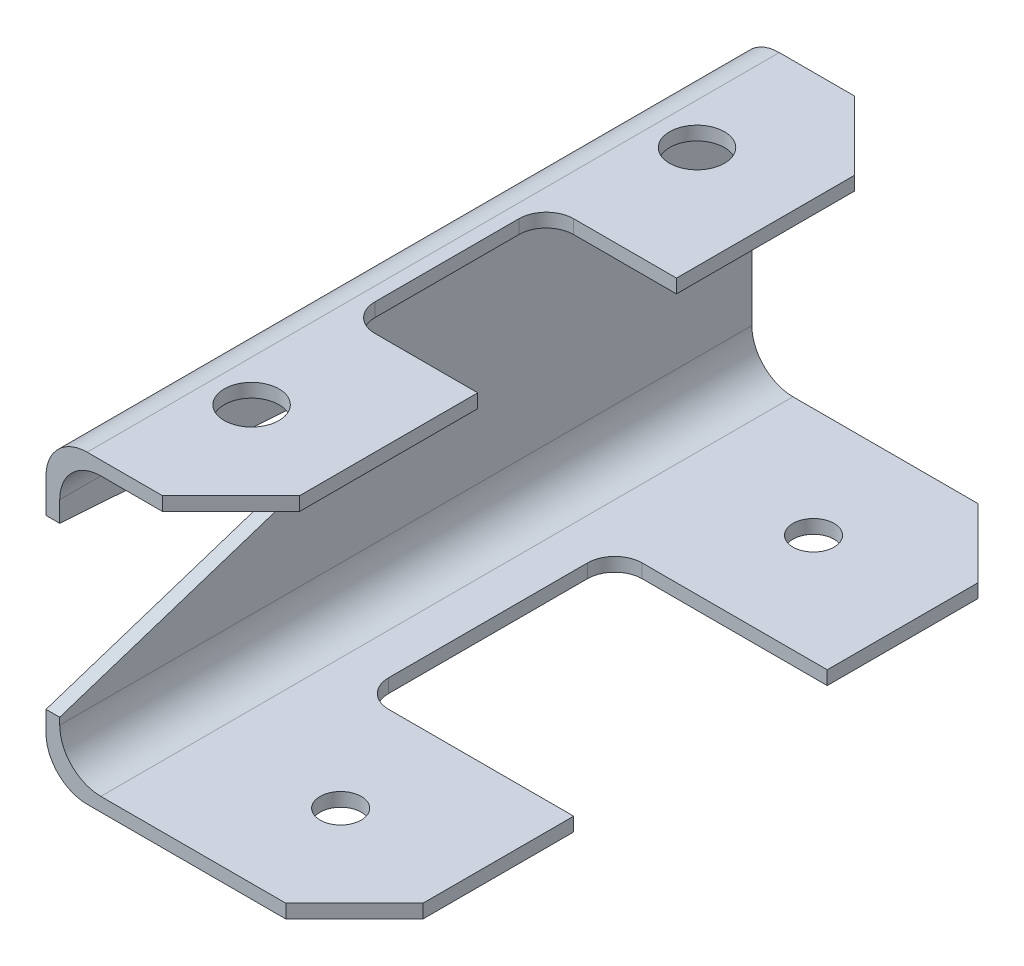
from build123d import *

# Parameters (mm, degrees)
BOSS_EXTRUDE1_DEPTH = 80.16875
CUT_EXTRUDE2_DEPTH  = 4.175
CUT_EXTRUDE3_REACH  = 72.644
SKETCH3_R           = 6.35
CUT_EXTRUDE4_REACH  = 5.175
SKETCH4_R           = 4.7625


with BuildPart() as part:
    # Sketch1 → Boss-Extrude1 (new body, symmetric)
    with BuildSketch(Plane.XY):
        with BuildLine():
            Line((0, 0), (-61.9125, 0))
            ThreePointArc((-61.9125, 0), (-68.647692091, 2.789807909), (-71.4375, 9.525))
            Line((-71.4375, 9.525), (-71.4375, 61.11875))
            ThreePointArc((-71.4375, 61.11875), (-68.647692091, 67.853942091), (-61.9125, 70.64375))
            Line((-61.9125, 70.64375), (-28.575, 70.64375))
            Line((-28.575, 70.64375), (-28.575, 67.46875))
            Line((-28.575, 67.46875), (-58.7375, 67.46875))
            ThreePointArc((-58.7375, 67.46875), (-65.472692091, 64.678942091), (-68.2625, 57.94375))
            Line((-68.2625, 57.94375), (-68.2625, 12.7))
            ThreePointArc((-68.2625, 12.7), (-65.472692091, 5.964807909), (-58.7375, 3.175))
            Line((-58.7375, 3.175), (0, 3.175))
            Line((0, 3.175), (0, 0))
        make_face()
    extrude(amount=BOSS_EXTRUDE1_DEPTH, both=True)

    # Sketch2 → Cut-Extrude2 (cut, through all)
    with BuildSketch(Plane(origin=(-68.2625, 0, 0), x_dir=(0, 0, -1), z_dir=(1, 0, 0))):
        with BuildLine():
            Line((-22.471470052, 49.193610415), (-80.16875, 53.18125))
            Line((-80.16875, 53.18125), (-80.16875, 14.2875))
            Line((-80.16875, 14.2875), (-20.557643239, 33.728685684))
            ThreePointArc((-20.557643239, 33.728685684), (-15.141341042, 42.249850944), (-22.471470052, 49.193610415))
        make_face()
    extrude(amount=-CUT_EXTRUDE2_DEPTH, mode=Mode.SUBTRACT)

    # Sketch3 → Cut-Extrude3 (cut, up to next)
    with BuildSketch(Plane(origin=(0, 70.64375, 0), x_dir=(1, 0, 0), z_dir=(0, 1, 0)), mode=Mode.PRIVATE) as cut_extrude3_sk1:
        with Locations((-52.3875, 51.59375)):
            Circle(SKETCH3_R)
    cut_extrude3_tool1 = extrude(cut_extrude3_sk1.sketch, amount=-CUT_EXTRUDE3_REACH, mode=Mode.PRIVATE) & part.part
    add(cut_extrude3_tool1.solids().sort_by_distance((-52.3875, 70.64375, -51.59375))[0], mode=Mode.SUBTRACT)
    # Sketch3 → Cut-Extrude3 (cut, up to next)
    with BuildSketch(Plane(origin=(0, 70.64375, 0), x_dir=(1, 0, 0), z_dir=(0, 1, 0)), mode=Mode.PRIVATE) as cut_extrude3_sk2:
        with Locations((-52.3875, -51.59375)):
            Circle(SKETCH3_R)
    cut_extrude3_tool2 = extrude(cut_extrude3_sk2.sketch, amount=-CUT_EXTRUDE3_REACH, mode=Mode.PRIVATE) & part.part
    add(cut_extrude3_tool2.solids().sort_by_distance((-52.3875, 70.64375, 51.59375))[0], mode=Mode.SUBTRACT)
    # Sketch3 → Cut-Extrude3 (cut, up to next)
    with BuildSketch(Plane(origin=(0, 70.64375, 0), x_dir=(1, 0, 0), z_dir=(0, 1, 0)), mode=Mode.PRIVATE) as cut_extrude3_sk3:
        Polygon((-44.45, 80.16875), (-28.575, 64.29375), (-28.575, 80.16875), align=None)
    cut_extrude3_tool3 = extrude(cut_extrude3_sk3.sketch, amount=-CUT_EXTRUDE3_REACH, mode=Mode.PRIVATE) & part.part
    add(cut_extrude3_tool3.solids().sort_by_distance((-33.866667, 70.64375, -74.877083))[0], mode=Mode.SUBTRACT)
    # Sketch3 → Cut-Extrude3 (cut, up to next)
    with BuildSketch(Plane(origin=(0, 70.64375, 0), x_dir=(1, 0, 0), z_dir=(0, 1, 0)), mode=Mode.PRIVATE) as cut_extrude3_sk4:
        Polygon((-28.575, -80.16875), (-28.575, -64.29375), (-44.45, -80.16875), align=None)
    cut_extrude3_tool4 = extrude(cut_extrude3_sk4.sketch, amount=-CUT_EXTRUDE3_REACH, mode=Mode.PRIVATE) & part.part
    add(cut_extrude3_tool4.solids().sort_by_distance((-33.866667, 70.64375, 74.877083))[0], mode=Mode.SUBTRACT)
    # Sketch3 → Cut-Extrude3 (cut, up to next)
    with BuildSketch(Plane(origin=(0, 70.64375, 0), x_dir=(1, 0, 0), z_dir=(0, 1, 0)), mode=Mode.PRIVATE) as cut_extrude3_sk5:
        Polygon((-15.875, 80.16875), (0, 64.29375), (0, 80.16875), align=None)
    cut_extrude3_tool5 = extrude(cut_extrude3_sk5.sketch, amount=-CUT_EXTRUDE3_REACH, mode=Mode.PRIVATE) & part.part
    add(cut_extrude3_tool5.solids().sort_by_distance((-5.291667, 70.64375, -74.877083))[0], mode=Mode.SUBTRACT)
    # Sketch3 → Cut-Extrude3 (cut, up to next)
    with BuildSketch(Plane(origin=(0, 70.64375, 0), x_dir=(1, 0, 0), z_dir=(0, 1, 0)), mode=Mode.PRIVATE) as cut_extrude3_sk6:
        Polygon((-15.875, -80.16875), (0, -80.16875), (0, -64.29375), align=None)
    cut_extrude3_tool6 = extrude(cut_extrude3_sk6.sketch, amount=-CUT_EXTRUDE3_REACH, mode=Mode.PRIVATE) & part.part
    add(cut_extrude3_tool6.solids().sort_by_distance((-5.291667, 70.64375, 74.877083))[0], mode=Mode.SUBTRACT)
    # Sketch3 → Cut-Extrude3 (cut, up to next)
    with BuildSketch(Plane(origin=(0, 70.64375, 0), x_dir=(1, 0, 0), z_dir=(0, 1, 0)), mode=Mode.PRIVATE) as cut_extrude3_sk7:
        with BuildLine():
            Line((-28.575, 23.01875), (-28.575, -23.01875))
            Line((-28.575, -23.01875), (-52.3875, -23.01875))
            ThreePointArc((-52.3875, -23.01875), (-56.877628061, -21.158878061), (-58.7375, -16.66875))
            Line((-58.7375, -16.66875), (-58.7375, 16.66875))
            ThreePointArc((-58.7375, 16.66875), (-56.877628061, 21.158878061), (-52.3875, 23.01875))
            Line((-52.3875, 23.01875), (-28.575, 23.01875))
        make_face()
    cut_extrude3_tool7 = extrude(cut_extrude3_sk7.sketch, amount=-CUT_EXTRUDE3_REACH, mode=Mode.PRIVATE) & part.part
    add(cut_extrude3_tool7.solids().sort_by_distance((-43.483817, 70.64375, 0))[0], mode=Mode.SUBTRACT)

    # Sketch4 → Cut-Extrude4 (cut, up to next)
    with BuildSketch(Plane(origin=(0, 3.175, 0), x_dir=(1, 0, 0), z_dir=(0, 1, 0)), mode=Mode.PRIVATE) as cut_extrude4_sk1:
        with Locations((-28.575, 54.76875)):
            Circle(SKETCH4_R)
    cut_extrude4_tool1 = extrude(cut_extrude4_sk1.sketch, amount=-CUT_EXTRUDE4_REACH, mode=Mode.PRIVATE) & part.part
    add(cut_extrude4_tool1.solids().sort_by_distance((-28.575, 3.175, -54.76875))[0], mode=Mode.SUBTRACT)
    # Sketch4 → Cut-Extrude4 (cut, up to next)
    with BuildSketch(Plane(origin=(0, 3.175, 0), x_dir=(1, 0, 0), z_dir=(0, 1, 0)), mode=Mode.PRIVATE) as cut_extrude4_sk2:
        with Locations((-28.575, -54.76875)):
            Circle(SKETCH4_R)
    cut_extrude4_tool2 = extrude(cut_extrude4_sk2.sketch, amount=-CUT_EXTRUDE4_REACH, mode=Mode.PRIVATE) & part.part
    add(cut_extrude4_tool2.solids().sort_by_distance((-28.575, 3.175, 54.76875))[0], mode=Mode.SUBTRACT)
    # Sketch4 → Cut-Extrude4 (cut, up to next)
    with BuildSketch(Plane(origin=(0, 3.175, 0), x_dir=(1, 0, 0), z_dir=(0, 1, 0)), mode=Mode.PRIVATE) as cut_extrude4_sk3:
        with BuildLine():
            Line((0, 29.36875), (-42.8625, 29.36875))
            ThreePointArc((-42.8625, 29.36875), (-47.352628061, 27.508878061), (-49.2125, 23.01875))
            Line((-49.2125, 23.01875), (-49.2125, -23.01875))
            ThreePointArc((-49.2125, -23.01875), (-47.352628061, -27.508878061), (-42.8625, -29.36875))
            Line((-42.8625, -29.36875), (0, -29.36875))
            Line((0, -29.36875), (0, 29.36875))
        make_face()
    cut_extrude4_tool3 = extrude(cut_extrude4_sk3.sketch, amount=-CUT_EXTRUDE4_REACH, mode=Mode.PRIVATE) & part.part
    add(cut_extrude4_tool3.solids().sort_by_distance((-24.466585, 3.175, 0))[0], mode=Mode.SUBTRACT)


solid = part.part
